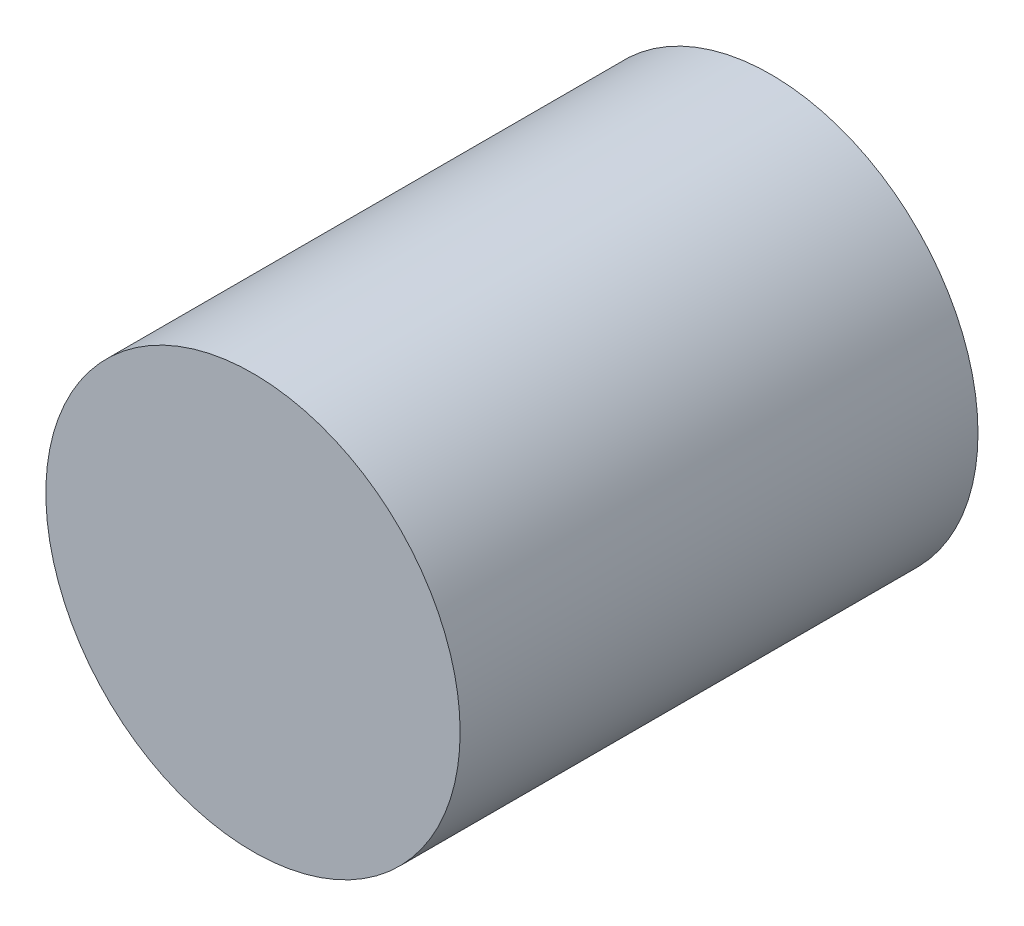
from build123d import *

# Parameters (mm, degrees)
SKETCH1_R           = 10
BOSS_EXTRUDE1_DEPTH = 12.5


with BuildPart() as part:
    # Sketch1 → Boss-Extrude1 (new body, symmetric)
    with BuildSketch(Plane.XY):
        Circle(SKETCH1_R)
    extrude(amount=BOSS_EXTRUDE1_DEPTH, both=True)


solid = part.part
